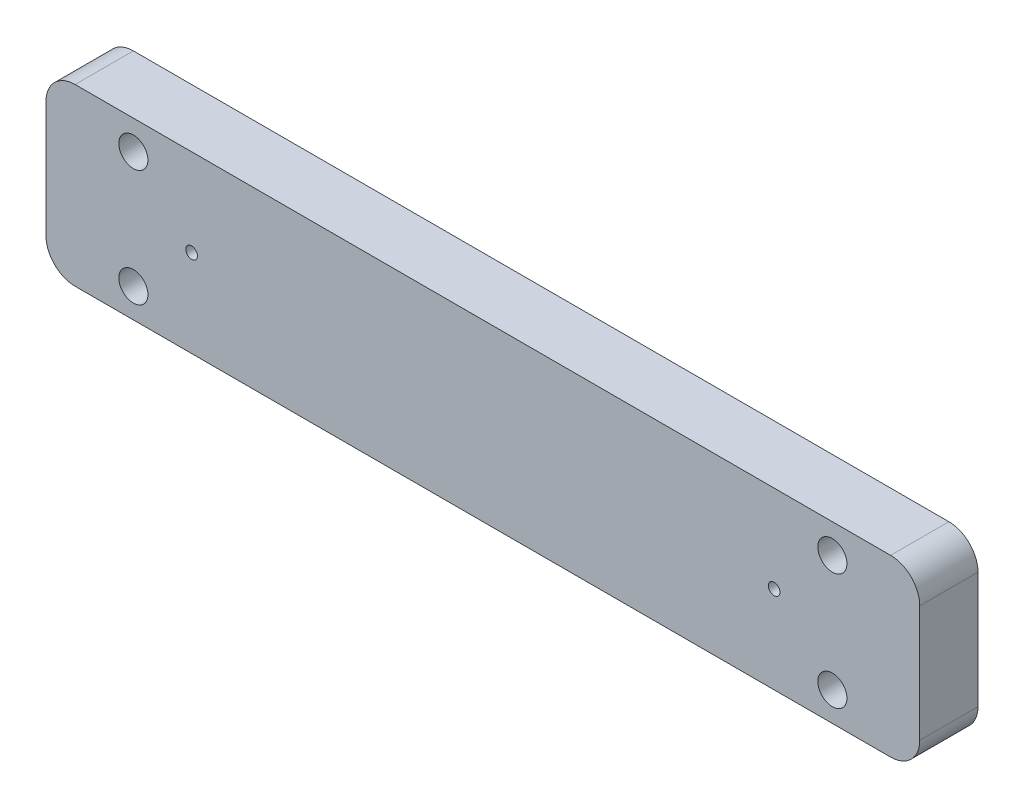
from build123d import *

# Parameters (mm, degrees)
SKETCH1_R           = 1
BOSS_EXTRUDE1_DEPTH = 10
SKETCH2_R           = 2.5
CUT_EXTRUDE1_DEPTH  = 11


with BuildPart() as part:
    # Sketch1 → Boss-Extrude1 (new body)
    with BuildSketch(Plane.XY):
        with BuildLine():
            Line((5, 0), (145, 0))
            ThreePointArc((145, 0), (148.535533906, 1.464466094), (150, 5))
            Line((150, 5), (150, 25))
            ThreePointArc((150, 25), (148.535533906, 28.535533906), (145, 30))
            Line((145, 30), (5, 30))
            ThreePointArc((5, 30), (1.464466094, 28.535533906), (0, 25))
            Line((0, 25), (0, 5))
            ThreePointArc((0, 5), (1.464466094, 1.464466094), (5, 0))
        make_face()
        with Locations((25, 15)):
            Circle(SKETCH1_R, mode=Mode.SUBTRACT)
        with Locations((125, 15)):
            Circle(SKETCH1_R, mode=Mode.SUBTRACT)
    extrude(amount=BOSS_EXTRUDE1_DEPTH)

    # Sketch2 → Cut-Extrude1 (cut, through all)
    with BuildSketch(Plane.XY.offset(10)):
        with Locations((15, 25)):
            Circle(SKETCH2_R)
        with Locations((15, 5)):
            Circle(SKETCH2_R)
        with Locations((135, 25)):
            Circle(SKETCH2_R)
        with Locations((135, 5)):
            Circle(SKETCH2_R)
    extrude(amount=-CUT_EXTRUDE1_DEPTH, mode=Mode.SUBTRACT)


solid = part.part
